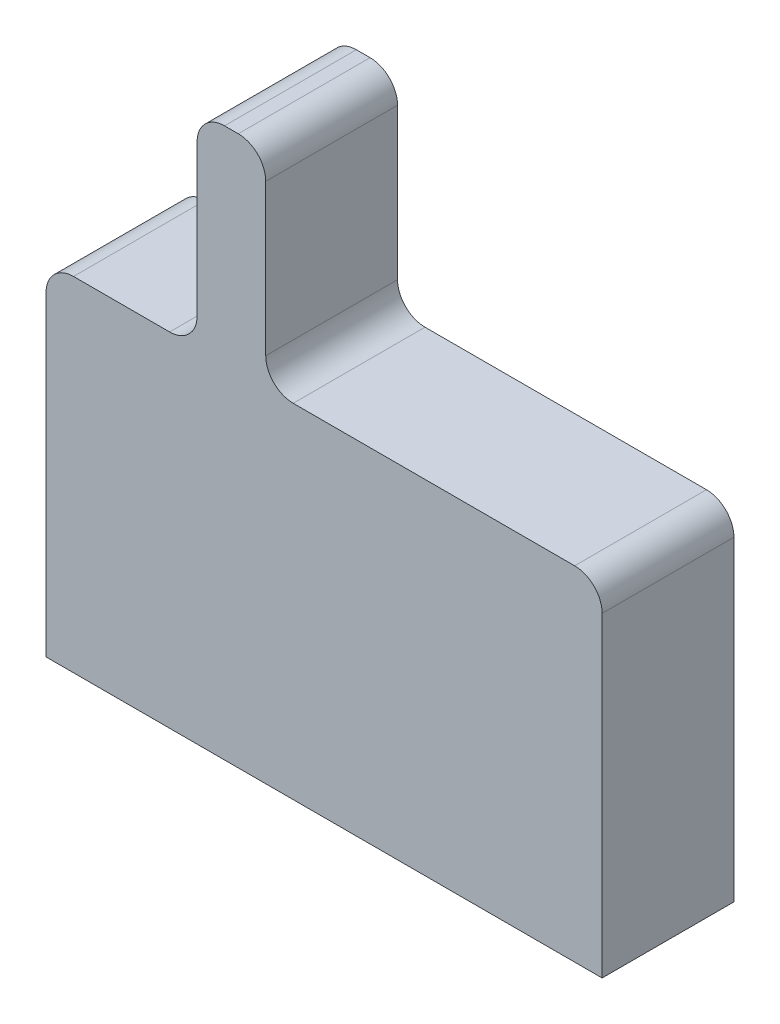
from build123d import *

# Parameters (mm, degrees)
BOSS_EXTRUDE1_DEPTH = 0.96
FILLET1_R           = 0.2


with BuildPart() as part:
    # Sketch1 → Boss-Extrude1 (new body)
    with BuildSketch(Plane.XY):
        Polygon((-0.925, 1.25), (-0.925, 2.75), (-0.425, 2.75), (-0.425, 1.25), (2.025, 1.25), (2.025, -1.25), (-2.025, -1.25), (-2.025, 1.25), align=None)
    extrude(amount=BOSS_EXTRUDE1_DEPTH)

    # Fillet1
    fillet1_edges = [part.edges().sort_by_distance(p)[0] for p in [
        (-2.025, 1.25, 0.48),
        (-0.925, 1.25, 0.48),
        (-0.925, 2.75, 0.48),
        (-0.425, 2.75, 0.48),
        (-0.425, 1.25, 0.48),
        (2.025, 1.25, 0.48),
    ]]
    fillet(fillet1_edges, radius=FILLET1_R)


solid = part.part
